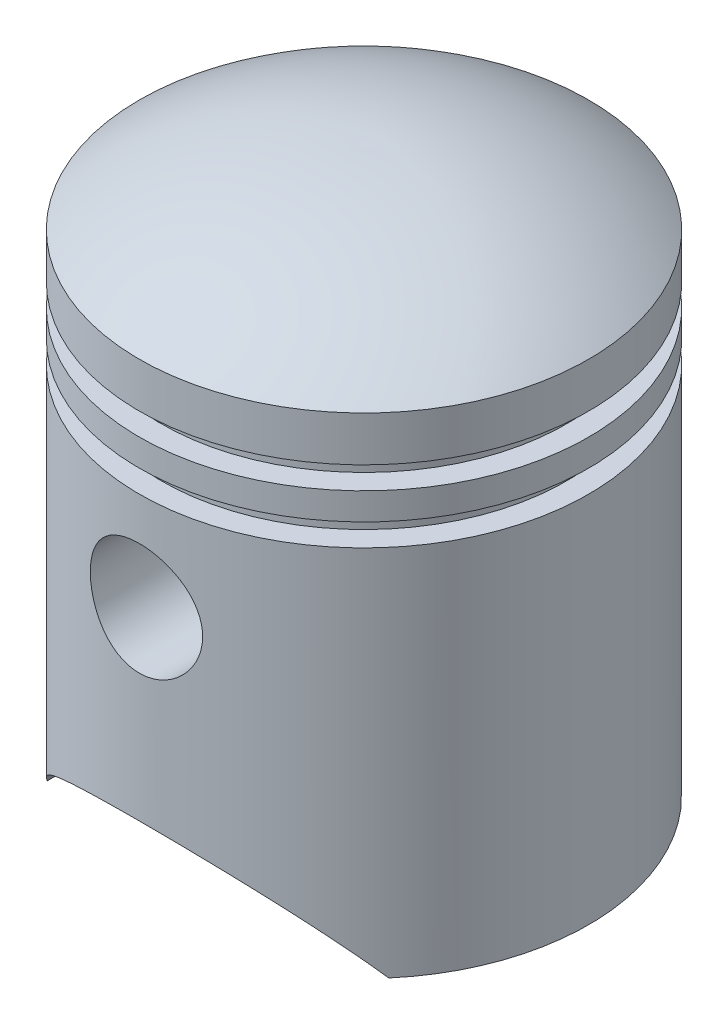
from build123d import *

# Parameters (mm, degrees)
CUT_EXTRUDE1_DEPTH  = 684.784
SKETCH3_R           = 158.75
CUT_EXTRUDE2_DEPTH  = 956.31
SKETCH5_R           = 184.15
SKETCH5_R_2         = 158.75
BOSS_EXTRUDE1_DEPTH = 279.4


with BuildPart() as part:
    # Sketch1 → Revolve2 (revolve)
    with BuildSketch(Plane.XY):
        with BuildLine():
            Line((0, 1587.5), (0, 1536.683816385))
            ThreePointArc((0, 1536.683816385), (306.565112988, 1495.022802298), (584.2, 1358.506583081))
            Line((584.2, 1358.506583081), (584.2, 1308.1))
            Line((584.2, 1308.1), (520.7, 1308.1))
            Line((520.7, 1308.1), (520.7, 1155.7))
            Line((520.7, 1155.7), (520.7, 1003.3))
            Line((520.7, 1003.3), (584.2, 1003.3))
            Line((584.2, 1003.3), (584.2, 0))
            Line((584.2, 0), (635, 0))
            Line((635, 0), (635, 1054.1))
            Line((635, 1054.1), (571.5, 1054.1))
            Line((571.5, 1054.1), (571.5, 1117.6))
            Line((571.5, 1117.6), (635, 1117.6))
            Line((635, 1117.6), (635, 1193.8))
            Line((635, 1193.8), (571.5, 1193.8))
            Line((571.5, 1193.8), (571.5, 1257.3))
            Line((571.5, 1257.3), (635, 1257.3))
            Line((635, 1257.3), (635, 1384.3))
            ThreePointArc((635, 1384.3), (334.642502957, 1539.470321739), (0, 1587.5))
        make_face()
    revolve(axis=Axis((0, 1587.5, 0), (0, -1, 0)))

    # Sketch2 → Cut-Extrude1 (cut, symmetric)
    with BuildSketch(Plane.XY):
        with BuildLine():
            Line((-482.6, 0), (482.6, 0))
            ThreePointArc((482.6, 0), (0, 254.118935078), (-482.6, 0))
        make_face()
    extrude(amount=CUT_EXTRUDE1_DEPTH, both=True, mode=Mode.SUBTRACT)

    # Sketch3 → Cut-Extrude2 (cut, symmetric)
    with BuildSketch(Plane.XY):
        with Locations((0, 774.7)):
            Circle(SKETCH3_R)
    extrude(amount=CUT_EXTRUDE2_DEPTH, both=True, mode=Mode.SUBTRACT)

    # Sketch5 → Boss-Extrude1 (add)
    with BuildSketch(Plane.XY.offset(304.8)):
        with Locations((0, 774.7)):
            Circle(SKETCH5_R)
        with Locations((0, 774.7)):
            Circle(SKETCH5_R_2, mode=Mode.SUBTRACT)
    boss_extrude1 = extrude(amount=BOSS_EXTRUDE1_DEPTH)

    # Mirror1: Boss-Extrude1 across plane
    add(boss_extrude1.mirror(Plane.XY))


solid = part.part
